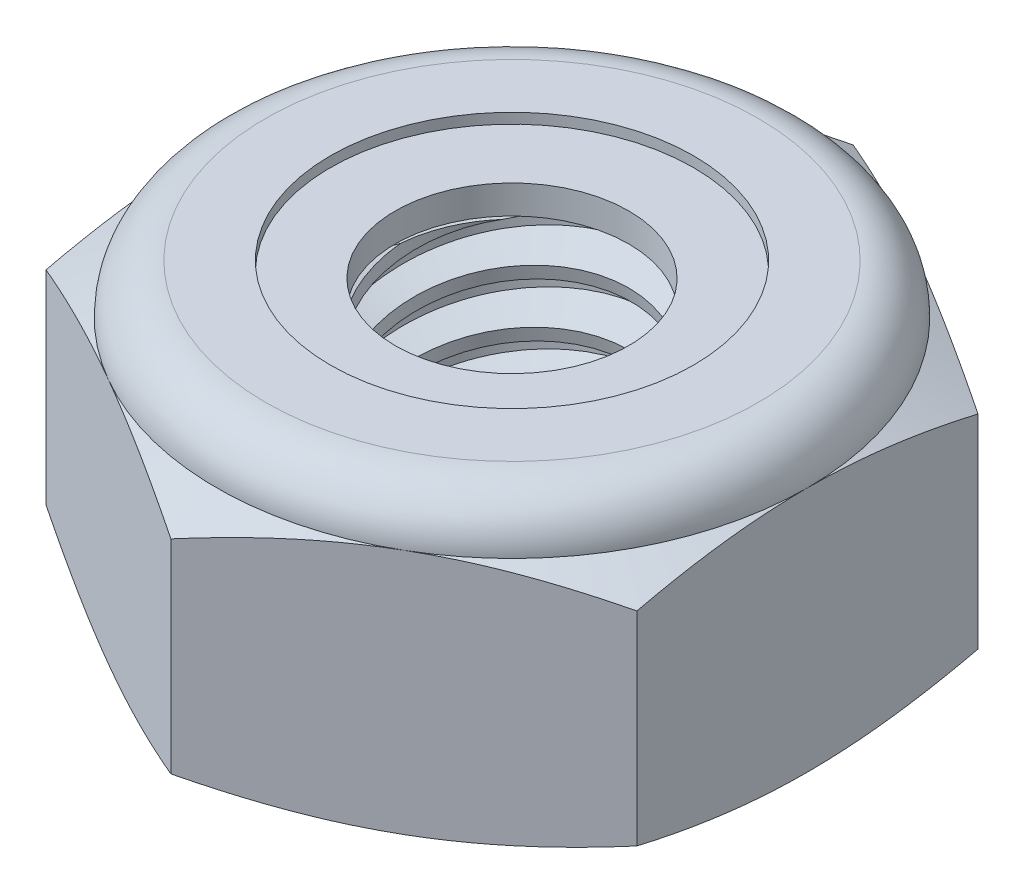
from build123d import *

# Parameters (mm, degrees)
EXTRUDE1_DEPTH      = 4.365625
SKETCH2_W           = 2.0828
SKETCH2_H           = 4.365625
LPATTERN1_COUNT     = 6
LPATTERN1_PITCH     = 0.79375
LPATTERN1_COL_COUNT = 2
LPATTERN1_COL_PITCH = 0.79375


with BuildPart() as part:
    # Sketch1 → Extrude1 (new body)
    with BuildSketch(Plane(origin=(0, 0, 0), x_dir=(1, 0, 0), z_dir=(0, 1, 0))):
        Polygon((0, 5.040989538), (-4.365625, 2.520494769), (-4.365625, -2.520494769), (0, -5.040989538), (4.365625, -2.520494769), (4.365625, 2.520494769), align=None)
    extrude(amount=EXTRUDE1_DEPTH)

    # Sketch4 → Cut-Revolve2 (revolve, cut)
    with BuildSketch(Plane(origin=(0, 0, 0), x_dir=(0, 0, -1), z_dir=(1, 0, 0))):
        Polygon((0, 4.365625), (2.0828, 4.365625), (1.725765218, 4.199136947), (1.725765218, 0.166488053), (2.0828, 0), (0, 0), align=None)
    revolve(axis=Axis((0, 4.365625, 0), (0, 1, 0)), mode=Mode.SUBTRACT)


with BuildPart() as body_2:
    # Sketch2 → Revolve1 (revolve)
    with BuildSketch(Plane(origin=(0, 0, 0), x_dir=(0, 0, -1), z_dir=(1, 0, 0))):
        with Locations((1.0414, 2.1828125)):
            Rectangle(SKETCH2_W, SKETCH2_H)
    revolve(axis=Axis((0, -2.0828, 0), (0, 1, 0)))

    # Sketch3 → Cut-Revolve1 (revolve, cut)
    with BuildSketch(Plane(origin=(0, 0, 0), x_dir=(0, 0, -1), z_dir=(1, 0, 0))):
        Polygon((2.101371857, 4.268159896), (2.231374854, 3.585904168), (1.762908932, 3.74914843), (1.725765218, 3.944078638), align=None)
    cut_revolve1 = revolve(axis=Axis((0, 4.365625, 0.162231854), (0, -0.982325457, -0.187180918)), mode=Mode.SUBTRACT)

    # LPattern1: Cut-Revolve1 ×6
    with Locations(*[(0, -i * LPATTERN1_PITCH, 0) for i in range(1, LPATTERN1_COUNT)]):
        add(cut_revolve1, mode=Mode.SUBTRACT)

    # LPattern1 col: Cut-Revolve1 ×2
    with Locations(*[(0, i * LPATTERN1_COL_PITCH, 0) for i in range(1, LPATTERN1_COL_COUNT)]):
        add(cut_revolve1, mode=Mode.SUBTRACT)


with BuildPart() as part_1:
    add(part.part)

    # Combine1: cut body 2
    add(body_2.part, mode=Mode.SUBTRACT)

    # Sketch5 → Cut-Revolve3 (revolve, cut)
    with BuildSketch(Plane(origin=(0, 0, 0), x_dir=(0, 0, -1), z_dir=(1, 0, 0))):
        with BuildLine():
            Line((0, 0), (4.365625, 0))
            Line((4.365625, 0), (5.040989538, 0.314927656))
            Line((5.040989538, 0.314927656), (5.040989538, 3.323093177))
            Line((5.040989538, 3.323093177), (4.365625, 3.638020833))
            ThreePointArc((4.365625, 3.638020833), (4.152514674, 4.152514674), (3.638020833, 4.365625))
            Line((3.638020833, 4.365625), (3.638020833, 5.635625))
            Line((3.638020833, 5.635625), (6.310989538, 5.635625))
            Line((6.310989538, 5.635625), (6.310989538, -1.27))
            Line((6.310989538, -1.27), (0, -1.27))
            Line((0, -1.27), (0, 0))
        make_face()
    revolve(axis=Axis((0, 0, 0), (0, 1, 0)), mode=Mode.SUBTRACT)

    # Sketch6 → Cut-Revolve4 (revolve, cut)
    with BuildSketch(Plane(origin=(0, 0, 0), x_dir=(0, 0, -1), z_dir=(1, 0, 0))):
        with BuildLine():
            Line((0, 3.638020833), (4.213225, 3.638020833))
            ThreePointArc((4.213225, 3.638020833), (4.0447516, 4.0447516), (3.638020833, 4.213225))
            Line((3.638020833, 4.213225), (2.681893026, 4.213225))
            Line((2.681893026, 4.213225), (2.681893026, 5.635625))
            Line((2.681893026, 5.635625), (0, 5.635625))
            Line((0, 5.635625), (0, 3.638020833))
        make_face()
    revolve(axis=Axis((0, 5.635625, 0), (0, 1, 0)), mode=Mode.SUBTRACT)


with BuildPart() as body_2_2:
    # Sketch7 → Revolve2 (revolve)
    with BuildSketch(Plane(origin=(0, 0, 0), x_dir=(0, 0, -1), z_dir=(1, 0, 0))):
        with BuildLine():
            Line((1.725765218, 3.714220833), (4.131172654, 3.714220833))
            ThreePointArc((4.131172654, 3.714220833), (3.962813876, 4.016854092), (3.638020833, 4.137025))
            Line((3.638020833, 4.137025), (1.725765218, 4.137025))
            Line((1.725765218, 4.137025), (1.725765218, 3.714220833))
        make_face()
    revolve(axis=Axis((0, 3.714220833, 0), (0, 1, 0)))


solid = Compound([part_1.part, body_2_2.part])
